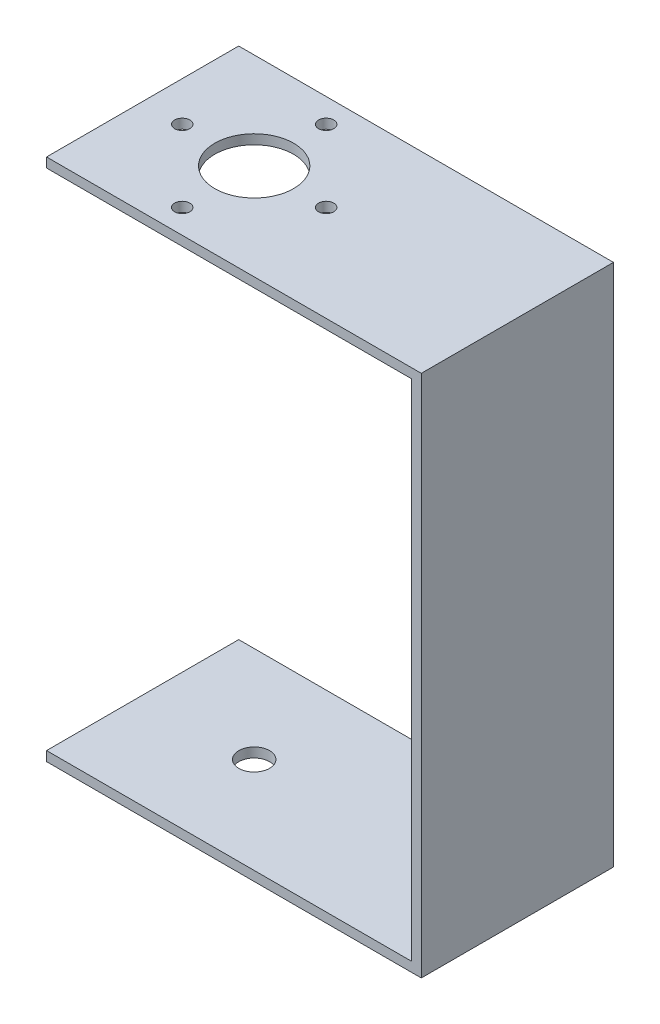
from build123d import *

# Parameters (mm, degrees)
SKETCH_1_W          = 20
SKETCH_1_H          = 54.5
EXTRUDE_1_DEPTH     = 1
SKETCH_2_W          = 20
SKETCH_2_H          = 1
EXTRUDE_2_DEPTH     = 38
SKETCH_3_W          = 20
SKETCH_3_H          = 1
EXTRUDE_3_DEPTH     = 38
SKETCH_4_R          = 4.1
CUT_EXTRUDE_1_DEPTH = 1
SKETCH_5_R          = 0.79
CUT_EXTRUDE_2_DEPTH = 1
SKETCH_6_R          = 0.79
CUT_EXTRUDE_3_DEPTH = 1
SKETCH_7_R          = 0.79
CUT_EXTRUDE_4_DEPTH = 1
SKETCH_8_R          = 0.79
CUT_EXTRUDE_5_DEPTH = 1
SKETCH_9_R          = 1.6
CUT_EXTRUDE_6_DEPTH = 1


with BuildPart() as part:
    # ｽｹｯﾁ1 → ﾎﾞｽ - 押し出し1 (new body)
    with BuildSketch(Plane(origin=(0, 0, 0), x_dir=(0, 0, -1), z_dir=(1, 0, 0))):
        with Locations((10, 27.25)):
            Rectangle(SKETCH_1_W, SKETCH_1_H)
    extrude(amount=EXTRUDE_1_DEPTH)

    # ｽｹｯﾁ2 → ﾎﾞｽ - 押し出し2 (add)
    with BuildSketch(Plane.ZY):
        with Locations((-10, 54)):
            Rectangle(SKETCH_2_W, SKETCH_2_H)
    extrude(amount=EXTRUDE_2_DEPTH)

    # ｽｹｯﾁ3 → ﾎﾞｽ - 押し出し3 (add)
    with BuildSketch(Plane.ZY):
        with Locations((-10, 0.5)):
            Rectangle(SKETCH_3_W, SKETCH_3_H)
    extrude(amount=EXTRUDE_3_DEPTH)

    # ｽｹｯﾁ4 → ｶｯﾄ - 押し出し1 (cut)
    with BuildSketch(Plane(origin=(0, 54.5, 0), x_dir=(1, 0, 0), z_dir=(0, 1, 0))):
        with Locations((-26.39, 10)):
            Circle(SKETCH_4_R)
    extrude(amount=-CUT_EXTRUDE_1_DEPTH, mode=Mode.SUBTRACT)

    # ｽｹｯﾁ5 → ｶｯﾄ - 押し出し2 (cut)
    with BuildSketch(Plane(origin=(0, 54.5, 0), x_dir=(1, 0, 0), z_dir=(0, 1, 0))):
        with Locations((-33.88, 10)):
            Circle(SKETCH_5_R)
    extrude(amount=-CUT_EXTRUDE_2_DEPTH, mode=Mode.SUBTRACT)

    # ｽｹｯﾁ6 → ｶｯﾄ - 押し出し3 (cut)
    with BuildSketch(Plane(origin=(0, 54.5, 0), x_dir=(1, 0, 0), z_dir=(0, 1, 0))):
        with Locations((-18.9, 10)):
            Circle(SKETCH_6_R)
    extrude(amount=-CUT_EXTRUDE_3_DEPTH, mode=Mode.SUBTRACT)

    # ｽｹｯﾁ7 → ｶｯﾄ - 押し出し4 (cut)
    with BuildSketch(Plane(origin=(0, 54.5, 0), x_dir=(1, 0, 0), z_dir=(0, 1, 0))):
        with Locations((-26.39, 2.51)):
            Circle(SKETCH_7_R)
    extrude(amount=-CUT_EXTRUDE_4_DEPTH, mode=Mode.SUBTRACT)

    # ｽｹｯﾁ8 → ｶｯﾄ - 押し出し5 (cut)
    with BuildSketch(Plane(origin=(0, 54.5, 0), x_dir=(1, 0, 0), z_dir=(0, 1, 0))):
        with Locations((-26.39, 17.49)):
            Circle(SKETCH_8_R)
    extrude(amount=-CUT_EXTRUDE_5_DEPTH, mode=Mode.SUBTRACT)

    # ｽｹｯﾁ9 → ｶｯﾄ - 押し出し6 (cut)
    with BuildSketch(Plane(origin=(0, 0, 0), x_dir=(-1, 0, 0), z_dir=(0, -1, 0))):
        with Locations((26.39, 10)):
            Circle(SKETCH_9_R)
    extrude(amount=-CUT_EXTRUDE_6_DEPTH, mode=Mode.SUBTRACT)


solid = part.part
